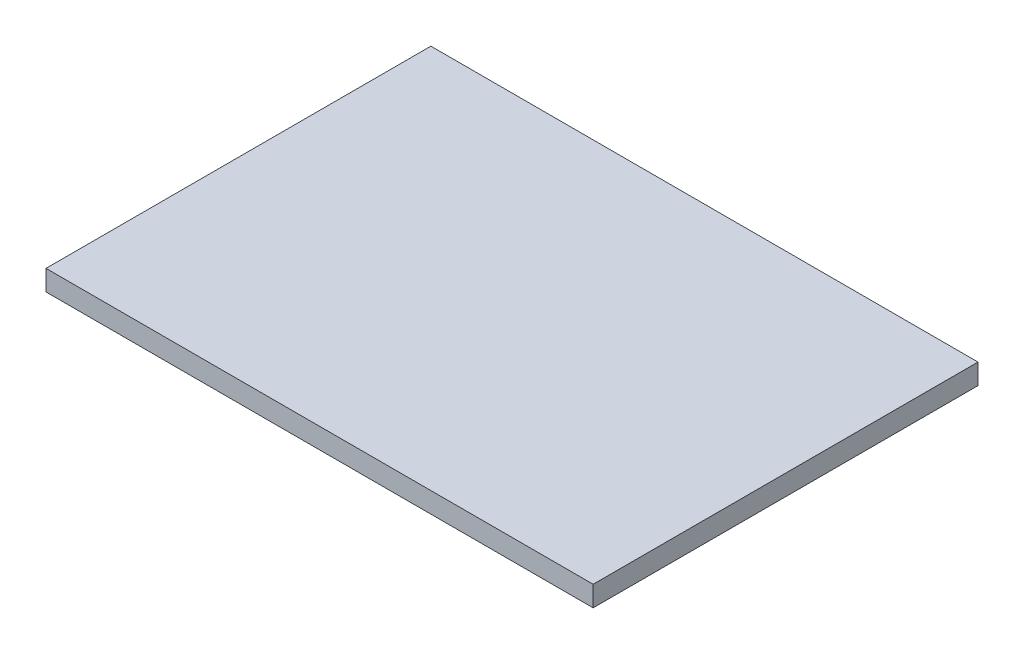
from build123d import *

# Parameters (mm, degrees)
SKETCH1_W           = 374.65
SKETCH1_H           = 263.525
BOSS_EXTRUDE1_DEPTH = 14


with BuildPart() as part:
    # Sketch1 → Boss-Extrude1 (new body)
    with BuildSketch(Plane(origin=(0, 0, 0), x_dir=(1, 0, 0), z_dir=(0, 1, 0))):
        Rectangle(SKETCH1_W, SKETCH1_H)
    extrude(amount=BOSS_EXTRUDE1_DEPTH)


solid = part.part
